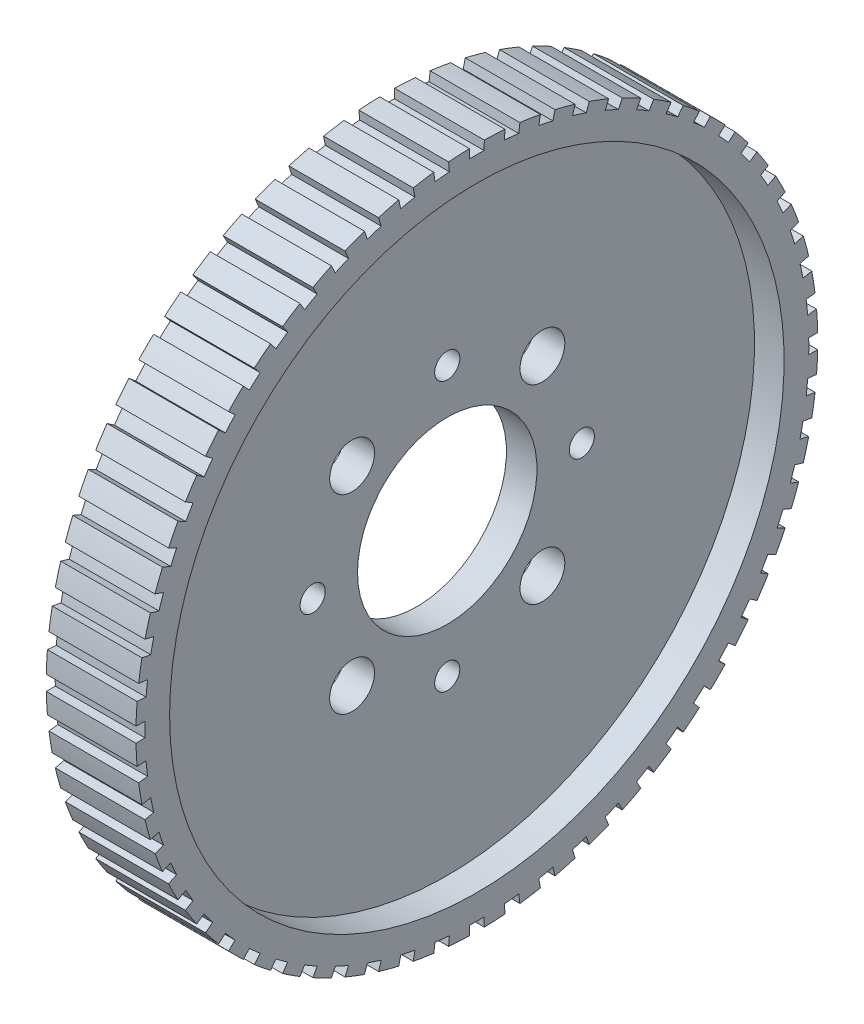
from build123d import *

# Parameters (mm, degrees)
SKETCH2_R          = 1.778
SKETCH2_R_2        = 3.175
CUT_EXTRUDE1_DEPTH = 9.509
CUT_EXTRUDE2_DEPTH = 13.7


with BuildPart() as part:
    # Sketch1 → Revolve1 (revolve)
    with BuildSketch(Plane.XY):
        Polygon((-2.159, 12.7), (2.159, 12.7), (2.159, 43.4975), (6.35, 43.4975), (6.35, 48.26), (-6.35, 48.26), (-6.35, 43.4975), (-2.159, 43.4975), align=None)
    revolve(axis=Axis((0, 0, 0), (1, 0, 0)))

    # Sketch2 → Cut-Extrude1 (cut, through all)
    with BuildSketch(Plane(origin=(2.159, 0, 0), x_dir=(0, 0, -1), z_dir=(1, 0, 0))):
        with Locations((0, 19.05)):
            Circle(SKETCH2_R)
        with Locations((19.05, 0)):
            Circle(SKETCH2_R)
        with Locations((0, -19.05)):
            Circle(SKETCH2_R)
        with Locations((-19.05, 0)):
            Circle(SKETCH2_R)
        with Locations((-13.470384182, 13.470384182)):
            Circle(SKETCH2_R_2)
        with Locations((13.470384182, 13.470384182)):
            Circle(SKETCH2_R_2)
        with Locations((13.470384182, -13.470384182)):
            Circle(SKETCH2_R_2)
        with Locations((-13.470384182, -13.470384182)):
            Circle(SKETCH2_R_2)
    extrude(amount=-CUT_EXTRUDE1_DEPTH, mode=Mode.SUBTRACT)

    # Sketch3 → Cut-Extrude2 (cut, through all)
    with BuildSketch(Plane(origin=(6.35, 0, 0), x_dir=(0, 0, -1), z_dir=(1, 0, 0))):
        with BuildLine():
            Line((-1.025081448, 46.978817652), (-1.080504445, 49.518817652))
            Line((-1.080504445, 49.518817652), (1.080504445, 49.518817652))
            Line((1.080504445, 49.518817652), (1.025081448, 46.978817652))
            ThreePointArc((1.025081448, 46.978817652), (0, 46.99), (-1.025081448, 46.978817652))
        make_face()
        with BuildLine():
            Line((4.101540584, 49.360491857), (6.250711241, 49.134604919))
            Line((6.250711241, 49.134604919), (5.93008956, 46.614312585))
            ThreePointArc((5.93008956, 46.614312585), (4.911792489, 46.732583863), (3.891157671, 46.828612962))
            Line((3.891157671, 46.828612962), (4.101540584, 49.360491857))
        make_face()
        with BuildLine():
            Line((9.238648275, 48.661362184), (11.352433936, 48.212063172))
            Line((11.352433936, 48.212063172), (10.770126369, 45.739091355))
            ThreePointArc((10.770126369, 45.739091355), (9.769770352, 45.963155758), (8.764764452, 46.165344189))
            Line((8.764764452, 46.165344189), (9.238648275, 48.661362184))
        make_face()
        with BuildLine():
            Line((14.274535403, 47.429088444), (16.329776989, 46.761299972))
            Line((16.329776989, 46.761299972), (15.492163421, 44.362743068))
            ThreePointArc((15.492163421, 44.362743068), (14.520708566, 44.690145701), (13.54234264, 44.996278244))
            Line((13.54234264, 44.996278244), (14.274535403, 47.429088444))
        make_face()
        with BuildLine():
            Line((19.154027733, 45.677171685), (21.128207589, 44.798210183))
            Line((21.128207589, 44.798210183), (20.044465088, 42.500347285))
            ThreePointArc((20.044465088, 42.500347285), (19.112554858, 42.927501055), (18.171548087, 43.334223659))
            Line((18.171548087, 43.334223659), (19.154027733, 45.677171685))
        make_face()
        with BuildLine():
            Line((23.823664528, 43.424806275), (25.695153124, 42.34430183))
            Line((25.695153124, 42.34430183), (24.377155401, 40.172308803))
            ThreePointArc((24.377155401, 40.172308803), (23.495, 40.694533724), (22.601662252, 41.197390251))
            Line((22.601662252, 41.197390251), (23.823664528, 43.424806275))
        make_face()
        with BuildLine():
            Line((28.232284269, 40.6966696), (29.980577186, 39.426460444))
            Line((29.980577186, 39.426460444), (28.442764498, 37.404134099))
            ThreePointArc((28.442764498, 37.404134099), (27.620029005, 38.015708566), (26.784147874, 38.609189614))
            Line((26.784147874, 38.609189614), (28.232284269, 40.6966696))
        make_face()
        with BuildLine():
            Line((32.331585195, 37.522651697), (33.937527769, 36.076654508))
            Line((33.937527769, 36.076654508), (32.196748715, 34.226151875))
            ThreePointArc((32.196748715, 34.226151875), (31.442447193, 34.920375349), (30.673180768, 35.597978616))
            Line((30.673180768, 35.597978616), (32.331585195, 37.522651697))
        make_face()
        with BuildLine():
            Line((36.076654508, 33.937527769), (37.522651697, 32.331585195))
            Line((37.522651697, 32.331585195), (35.597978616, 30.673180768))
            ThreePointArc((35.597978616, 30.673180768), (34.920375349, 31.442447193), (34.226151875, 32.196748715))
            Line((34.226151875, 32.196748715), (36.076654508, 33.937527769))
        make_face()
        with BuildLine():
            Line((39.426460444, 29.980577186), (40.6966696, 28.232284269))
            Line((40.6966696, 28.232284269), (38.609189614, 26.784147874))
            ThreePointArc((38.609189614, 26.784147874), (38.015708566, 27.620029005), (37.404134099, 28.442764498))
            Line((37.404134099, 28.442764498), (39.426460444, 29.980577186))
        make_face()
        with BuildLine():
            Line((42.34430183, 25.695153124), (43.424806275, 23.823664528))
            Line((43.424806275, 23.823664528), (41.197390251, 22.601662252))
            ThreePointArc((41.197390251, 22.601662252), (40.694533724, 23.495), (40.172308803, 24.377155401))
            Line((40.172308803, 24.377155401), (42.34430183, 25.695153124))
        make_face()
        with BuildLine():
            Line((44.798210183, 21.128207589), (45.677171685, 19.154027733))
            Line((45.677171685, 19.154027733), (43.334223659, 18.171548087))
            ThreePointArc((43.334223659, 18.171548087), (42.927501055, 19.112554858), (42.500347285, 20.044465088))
            Line((42.500347285, 20.044465088), (44.798210183, 21.128207589))
        make_face()
        with BuildLine():
            Line((46.761299972, 16.329776989), (47.429088444, 14.274535403))
            Line((47.429088444, 14.274535403), (44.996278244, 13.54234264))
            ThreePointArc((44.996278244, 13.54234264), (44.690145701, 14.520708566), (44.362743068, 15.492163421))
            Line((44.362743068, 15.492163421), (46.761299972, 16.329776989))
        make_face()
        with BuildLine():
            Line((48.212063172, 11.352433936), (48.661362184, 9.238648275))
            Line((48.661362184, 9.238648275), (46.165344189, 8.764764452))
            ThreePointArc((46.165344189, 8.764764452), (45.963155758, 9.769770352), (45.739091355, 10.770126369))
            Line((45.739091355, 10.770126369), (48.212063172, 11.352433936))
        make_face()
        with BuildLine():
            Line((49.134604919, 6.250711241), (49.360491857, 4.101540584))
            Line((49.360491857, 4.101540584), (46.828612962, 3.891157671))
            ThreePointArc((46.828612962, 3.891157671), (46.732583863, 4.911792489), (46.614312585, 5.93008956))
            Line((46.614312585, 5.93008956), (49.134604919, 6.250711241))
        make_face()
        with BuildLine():
            Line((49.518817652, 1.080504445), (49.518817652, -1.080504445))
            Line((49.518817652, -1.080504445), (46.978817652, -1.025081448))
            ThreePointArc((46.978817652, -1.025081448), (46.99, 0), (46.978817652, 1.025081448))
            Line((46.978817652, 1.025081448), (49.518817652, 1.080504445))
        make_face()
        with BuildLine():
            Line((49.360491857, -4.101540584), (49.134604919, -6.250711241))
            Line((49.134604919, -6.250711241), (46.614312585, -5.93008956))
            ThreePointArc((46.614312585, -5.93008956), (46.732583863, -4.911792489), (46.828612962, -3.891157671))
            Line((46.828612962, -3.891157671), (49.360491857, -4.101540584))
        make_face()
        with BuildLine():
            Line((48.661362184, -9.238648275), (48.212063172, -11.352433936))
            Line((48.212063172, -11.352433936), (45.739091355, -10.770126369))
            ThreePointArc((45.739091355, -10.770126369), (45.963155758, -9.769770352), (46.165344189, -8.764764452))
            Line((46.165344189, -8.764764452), (48.661362184, -9.238648275))
        make_face()
        with BuildLine():
            Line((47.429088444, -14.274535403), (46.761299972, -16.329776989))
            Line((46.761299972, -16.329776989), (44.362743068, -15.492163421))
            ThreePointArc((44.362743068, -15.492163421), (44.690145701, -14.520708566), (44.996278244, -13.54234264))
            Line((44.996278244, -13.54234264), (47.429088444, -14.274535403))
        make_face()
        with BuildLine():
            Line((45.677171685, -19.154027733), (44.798210183, -21.128207589))
            Line((44.798210183, -21.128207589), (42.500347285, -20.044465088))
            ThreePointArc((42.500347285, -20.044465088), (42.927501055, -19.112554858), (43.334223659, -18.171548087))
            Line((43.334223659, -18.171548087), (45.677171685, -19.154027733))
        make_face()
        with BuildLine():
            Line((43.424806275, -23.823664528), (42.34430183, -25.695153124))
            Line((42.34430183, -25.695153124), (40.172308803, -24.377155401))
            ThreePointArc((40.172308803, -24.377155401), (40.694533724, -23.495), (41.197390251, -22.601662252))
            Line((41.197390251, -22.601662252), (43.424806275, -23.823664528))
        make_face()
        with BuildLine():
            Line((40.6966696, -28.232284269), (39.426460444, -29.980577186))
            Line((39.426460444, -29.980577186), (37.404134099, -28.442764498))
            ThreePointArc((37.404134099, -28.442764498), (38.015708566, -27.620029005), (38.609189614, -26.784147874))
            Line((38.609189614, -26.784147874), (40.6966696, -28.232284269))
        make_face()
        with BuildLine():
            Line((37.522651697, -32.331585195), (36.076654508, -33.937527769))
            Line((36.076654508, -33.937527769), (34.226151875, -32.196748715))
            ThreePointArc((34.226151875, -32.196748715), (34.920375349, -31.442447193), (35.597978616, -30.673180768))
            Line((35.597978616, -30.673180768), (37.522651697, -32.331585195))
        make_face()
        with BuildLine():
            Line((33.937527769, -36.076654508), (32.331585195, -37.522651697))
            Line((32.331585195, -37.522651697), (30.673180768, -35.597978616))
            ThreePointArc((30.673180768, -35.597978616), (31.442447193, -34.920375349), (32.196748715, -34.226151875))
            Line((32.196748715, -34.226151875), (33.937527769, -36.076654508))
        make_face()
        with BuildLine():
            Line((29.980577186, -39.426460444), (28.232284269, -40.6966696))
            Line((28.232284269, -40.6966696), (26.784147874, -38.609189614))
            ThreePointArc((26.784147874, -38.609189614), (27.620029005, -38.015708566), (28.442764498, -37.404134099))
            Line((28.442764498, -37.404134099), (29.980577186, -39.426460444))
        make_face()
        with BuildLine():
            Line((25.695153124, -42.34430183), (23.823664528, -43.424806275))
            Line((23.823664528, -43.424806275), (22.601662252, -41.197390251))
            ThreePointArc((22.601662252, -41.197390251), (23.495, -40.694533724), (24.377155401, -40.172308803))
            Line((24.377155401, -40.172308803), (25.695153124, -42.34430183))
        make_face()
        with BuildLine():
            Line((21.128207589, -44.798210183), (19.154027733, -45.677171685))
            Line((19.154027733, -45.677171685), (18.171548087, -43.334223659))
            ThreePointArc((18.171548087, -43.334223659), (19.112554858, -42.927501055), (20.044465088, -42.500347285))
            Line((20.044465088, -42.500347285), (21.128207589, -44.798210183))
        make_face()
        with BuildLine():
            Line((16.329776989, -46.761299972), (14.274535403, -47.429088444))
            Line((14.274535403, -47.429088444), (13.54234264, -44.996278244))
            ThreePointArc((13.54234264, -44.996278244), (14.520708566, -44.690145701), (15.492163421, -44.362743068))
            Line((15.492163421, -44.362743068), (16.329776989, -46.761299972))
        make_face()
        with BuildLine():
            Line((11.352433936, -48.212063172), (9.238648275, -48.661362184))
            Line((9.238648275, -48.661362184), (8.764764452, -46.165344189))
            ThreePointArc((8.764764452, -46.165344189), (9.769770352, -45.963155758), (10.770126369, -45.739091355))
            Line((10.770126369, -45.739091355), (11.352433936, -48.212063172))
        make_face()
        with BuildLine():
            Line((6.250711241, -49.134604919), (4.101540584, -49.360491857))
            Line((4.101540584, -49.360491857), (3.891157671, -46.828612962))
            ThreePointArc((3.891157671, -46.828612962), (4.911792489, -46.732583863), (5.93008956, -46.614312585))
            Line((5.93008956, -46.614312585), (6.250711241, -49.134604919))
        make_face()
        with BuildLine():
            Line((1.080504445, -49.518817652), (-1.080504445, -49.518817652))
            Line((-1.080504445, -49.518817652), (-1.025081448, -46.978817652))
            ThreePointArc((-1.025081448, -46.978817652), (0, -46.99), (1.025081448, -46.978817652))
            Line((1.025081448, -46.978817652), (1.080504445, -49.518817652))
        make_face()
        with BuildLine():
            Line((-4.101540584, -49.360491857), (-6.250711241, -49.134604919))
            Line((-6.250711241, -49.134604919), (-5.93008956, -46.614312585))
            ThreePointArc((-5.93008956, -46.614312585), (-4.911792489, -46.732583863), (-3.891157671, -46.828612962))
            Line((-3.891157671, -46.828612962), (-4.101540584, -49.360491857))
        make_face()
        with BuildLine():
            Line((-9.238648275, -48.661362184), (-11.352433936, -48.212063172))
            Line((-11.352433936, -48.212063172), (-10.770126369, -45.739091355))
            ThreePointArc((-10.770126369, -45.739091355), (-9.769770352, -45.963155758), (-8.764764452, -46.165344189))
            Line((-8.764764452, -46.165344189), (-9.238648275, -48.661362184))
        make_face()
        with BuildLine():
            Line((-14.274535403, -47.429088444), (-16.329776989, -46.761299972))
            Line((-16.329776989, -46.761299972), (-15.492163421, -44.362743068))
            ThreePointArc((-15.492163421, -44.362743068), (-14.520708566, -44.690145701), (-13.54234264, -44.996278244))
            Line((-13.54234264, -44.996278244), (-14.274535403, -47.429088444))
        make_face()
        with BuildLine():
            Line((-19.154027733, -45.677171685), (-21.128207589, -44.798210183))
            Line((-21.128207589, -44.798210183), (-20.044465088, -42.500347285))
            ThreePointArc((-20.044465088, -42.500347285), (-19.112554858, -42.927501055), (-18.171548087, -43.334223659))
            Line((-18.171548087, -43.334223659), (-19.154027733, -45.677171685))
        make_face()
        with BuildLine():
            Line((-23.823664528, -43.424806275), (-25.695153124, -42.34430183))
            Line((-25.695153124, -42.34430183), (-24.377155401, -40.172308803))
            ThreePointArc((-24.377155401, -40.172308803), (-23.495, -40.694533724), (-22.601662252, -41.197390251))
            Line((-22.601662252, -41.197390251), (-23.823664528, -43.424806275))
        make_face()
        with BuildLine():
            Line((-28.232284269, -40.6966696), (-29.980577186, -39.426460444))
            Line((-29.980577186, -39.426460444), (-28.442764498, -37.404134099))
            ThreePointArc((-28.442764498, -37.404134099), (-27.620029005, -38.015708566), (-26.784147874, -38.609189614))
            Line((-26.784147874, -38.609189614), (-28.232284269, -40.6966696))
        make_face()
        with BuildLine():
            Line((-32.331585195, -37.522651697), (-33.937527769, -36.076654508))
            Line((-33.937527769, -36.076654508), (-32.196748715, -34.226151875))
            ThreePointArc((-32.196748715, -34.226151875), (-31.442447193, -34.920375349), (-30.673180768, -35.597978616))
            Line((-30.673180768, -35.597978616), (-32.331585195, -37.522651697))
        make_face()
        with BuildLine():
            Line((-36.076654508, -33.937527769), (-37.522651697, -32.331585195))
            Line((-37.522651697, -32.331585195), (-35.597978616, -30.673180768))
            ThreePointArc((-35.597978616, -30.673180768), (-34.920375349, -31.442447193), (-34.226151875, -32.196748715))
            Line((-34.226151875, -32.196748715), (-36.076654508, -33.937527769))
        make_face()
        with BuildLine():
            Line((-39.426460444, -29.980577186), (-40.6966696, -28.232284269))
            Line((-40.6966696, -28.232284269), (-38.609189614, -26.784147874))
            ThreePointArc((-38.609189614, -26.784147874), (-38.015708566, -27.620029005), (-37.404134099, -28.442764498))
            Line((-37.404134099, -28.442764498), (-39.426460444, -29.980577186))
        make_face()
        with BuildLine():
            Line((-42.34430183, -25.695153124), (-43.424806275, -23.823664528))
            Line((-43.424806275, -23.823664528), (-41.197390251, -22.601662252))
            ThreePointArc((-41.197390251, -22.601662252), (-40.694533724, -23.495), (-40.172308803, -24.377155401))
            Line((-40.172308803, -24.377155401), (-42.34430183, -25.695153124))
        make_face()
        with BuildLine():
            Line((-44.798210183, -21.128207589), (-45.677171685, -19.154027733))
            Line((-45.677171685, -19.154027733), (-43.334223659, -18.171548087))
            ThreePointArc((-43.334223659, -18.171548087), (-42.927501055, -19.112554858), (-42.500347285, -20.044465088))
            Line((-42.500347285, -20.044465088), (-44.798210183, -21.128207589))
        make_face()
        with BuildLine():
            Line((-46.761299972, -16.329776989), (-47.429088444, -14.274535403))
            Line((-47.429088444, -14.274535403), (-44.996278244, -13.54234264))
            ThreePointArc((-44.996278244, -13.54234264), (-44.690145701, -14.520708566), (-44.362743068, -15.492163421))
            Line((-44.362743068, -15.492163421), (-46.761299972, -16.329776989))
        make_face()
        with BuildLine():
            Line((-48.212063172, -11.352433936), (-48.661362184, -9.238648275))
            Line((-48.661362184, -9.238648275), (-46.165344189, -8.764764452))
            ThreePointArc((-46.165344189, -8.764764452), (-45.963155758, -9.769770352), (-45.739091355, -10.770126369))
            Line((-45.739091355, -10.770126369), (-48.212063172, -11.352433936))
        make_face()
        with BuildLine():
            Line((-49.134604919, -6.250711241), (-49.360491857, -4.101540584))
            Line((-49.360491857, -4.101540584), (-46.828612962, -3.891157671))
            ThreePointArc((-46.828612962, -3.891157671), (-46.732583863, -4.911792489), (-46.614312585, -5.93008956))
            Line((-46.614312585, -5.93008956), (-49.134604919, -6.250711241))
        make_face()
        with BuildLine():
            Line((-49.518817652, -1.080504445), (-49.518817652, 1.080504445))
            Line((-49.518817652, 1.080504445), (-46.978817652, 1.025081448))
            ThreePointArc((-46.978817652, 1.025081448), (-46.99, 0), (-46.978817652, -1.025081448))
            Line((-46.978817652, -1.025081448), (-49.518817652, -1.080504445))
        make_face()
        with BuildLine():
            Line((-49.360491857, 4.101540584), (-49.134604919, 6.250711241))
            Line((-49.134604919, 6.250711241), (-46.614312585, 5.93008956))
            ThreePointArc((-46.614312585, 5.93008956), (-46.732583863, 4.911792489), (-46.828612962, 3.891157671))
            Line((-46.828612962, 3.891157671), (-49.360491857, 4.101540584))
        make_face()
        with BuildLine():
            Line((-48.661362184, 9.238648275), (-48.212063172, 11.352433936))
            Line((-48.212063172, 11.352433936), (-45.739091355, 10.770126369))
            ThreePointArc((-45.739091355, 10.770126369), (-45.963155758, 9.769770352), (-46.165344189, 8.764764452))
            Line((-46.165344189, 8.764764452), (-48.661362184, 9.238648275))
        make_face()
        with BuildLine():
            Line((-47.429088444, 14.274535403), (-46.761299972, 16.329776989))
            Line((-46.761299972, 16.329776989), (-44.362743068, 15.492163421))
            ThreePointArc((-44.362743068, 15.492163421), (-44.690145701, 14.520708566), (-44.996278244, 13.54234264))
            Line((-44.996278244, 13.54234264), (-47.429088444, 14.274535403))
        make_face()
        with BuildLine():
            Line((-45.677171685, 19.154027733), (-44.798210183, 21.128207589))
            Line((-44.798210183, 21.128207589), (-42.500347285, 20.044465088))
            ThreePointArc((-42.500347285, 20.044465088), (-42.927501055, 19.112554858), (-43.334223659, 18.171548087))
            Line((-43.334223659, 18.171548087), (-45.677171685, 19.154027733))
        make_face()
        with BuildLine():
            Line((-43.424806275, 23.823664528), (-42.34430183, 25.695153124))
            Line((-42.34430183, 25.695153124), (-40.172308803, 24.377155401))
            ThreePointArc((-40.172308803, 24.377155401), (-40.694533724, 23.495), (-41.197390251, 22.601662252))
            Line((-41.197390251, 22.601662252), (-43.424806275, 23.823664528))
        make_face()
        with BuildLine():
            Line((-40.6966696, 28.232284269), (-39.426460444, 29.980577186))
            Line((-39.426460444, 29.980577186), (-37.404134099, 28.442764498))
            ThreePointArc((-37.404134099, 28.442764498), (-38.015708566, 27.620029005), (-38.609189614, 26.784147874))
            Line((-38.609189614, 26.784147874), (-40.6966696, 28.232284269))
        make_face()
        with BuildLine():
            Line((-37.522651697, 32.331585195), (-36.076654508, 33.937527769))
            Line((-36.076654508, 33.937527769), (-34.226151875, 32.196748715))
            ThreePointArc((-34.226151875, 32.196748715), (-34.920375349, 31.442447193), (-35.597978616, 30.673180768))
            Line((-35.597978616, 30.673180768), (-37.522651697, 32.331585195))
        make_face()
        with BuildLine():
            Line((-33.937527769, 36.076654508), (-32.331585195, 37.522651697))
            Line((-32.331585195, 37.522651697), (-30.673180768, 35.597978616))
            ThreePointArc((-30.673180768, 35.597978616), (-31.442447193, 34.920375349), (-32.196748715, 34.226151875))
            Line((-32.196748715, 34.226151875), (-33.937527769, 36.076654508))
        make_face()
        with BuildLine():
            Line((-29.980577186, 39.426460444), (-28.232284269, 40.6966696))
            Line((-28.232284269, 40.6966696), (-26.784147874, 38.609189614))
            ThreePointArc((-26.784147874, 38.609189614), (-27.620029005, 38.015708566), (-28.442764498, 37.404134099))
            Line((-28.442764498, 37.404134099), (-29.980577186, 39.426460444))
        make_face()
        with BuildLine():
            Line((-25.695153124, 42.34430183), (-23.823664528, 43.424806275))
            Line((-23.823664528, 43.424806275), (-22.601662252, 41.197390251))
            ThreePointArc((-22.601662252, 41.197390251), (-23.495, 40.694533724), (-24.377155401, 40.172308803))
            Line((-24.377155401, 40.172308803), (-25.695153124, 42.34430183))
        make_face()
        with BuildLine():
            Line((-21.128207589, 44.798210183), (-19.154027733, 45.677171685))
            Line((-19.154027733, 45.677171685), (-18.171548087, 43.334223659))
            ThreePointArc((-18.171548087, 43.334223659), (-19.112554858, 42.927501055), (-20.044465088, 42.500347285))
            Line((-20.044465088, 42.500347285), (-21.128207589, 44.798210183))
        make_face()
        with BuildLine():
            Line((-16.329776989, 46.761299972), (-14.274535403, 47.429088444))
            Line((-14.274535403, 47.429088444), (-13.54234264, 44.996278244))
            ThreePointArc((-13.54234264, 44.996278244), (-14.520708566, 44.690145701), (-15.492163421, 44.362743068))
            Line((-15.492163421, 44.362743068), (-16.329776989, 46.761299972))
        make_face()
        with BuildLine():
            Line((-11.352433936, 48.212063172), (-9.238648275, 48.661362184))
            Line((-9.238648275, 48.661362184), (-8.764764452, 46.165344189))
            ThreePointArc((-8.764764452, 46.165344189), (-9.769770352, 45.963155758), (-10.770126369, 45.739091355))
            Line((-10.770126369, 45.739091355), (-11.352433936, 48.212063172))
        make_face()
        with BuildLine():
            Line((-6.250711241, 49.134604919), (-4.101540584, 49.360491857))
            Line((-4.101540584, 49.360491857), (-3.891157671, 46.828612962))
            ThreePointArc((-3.891157671, 46.828612962), (-4.911792489, 46.732583863), (-5.93008956, 46.614312585))
            Line((-5.93008956, 46.614312585), (-6.250711241, 49.134604919))
        make_face()
    extrude(amount=-CUT_EXTRUDE2_DEPTH, mode=Mode.SUBTRACT)


solid = part.part
